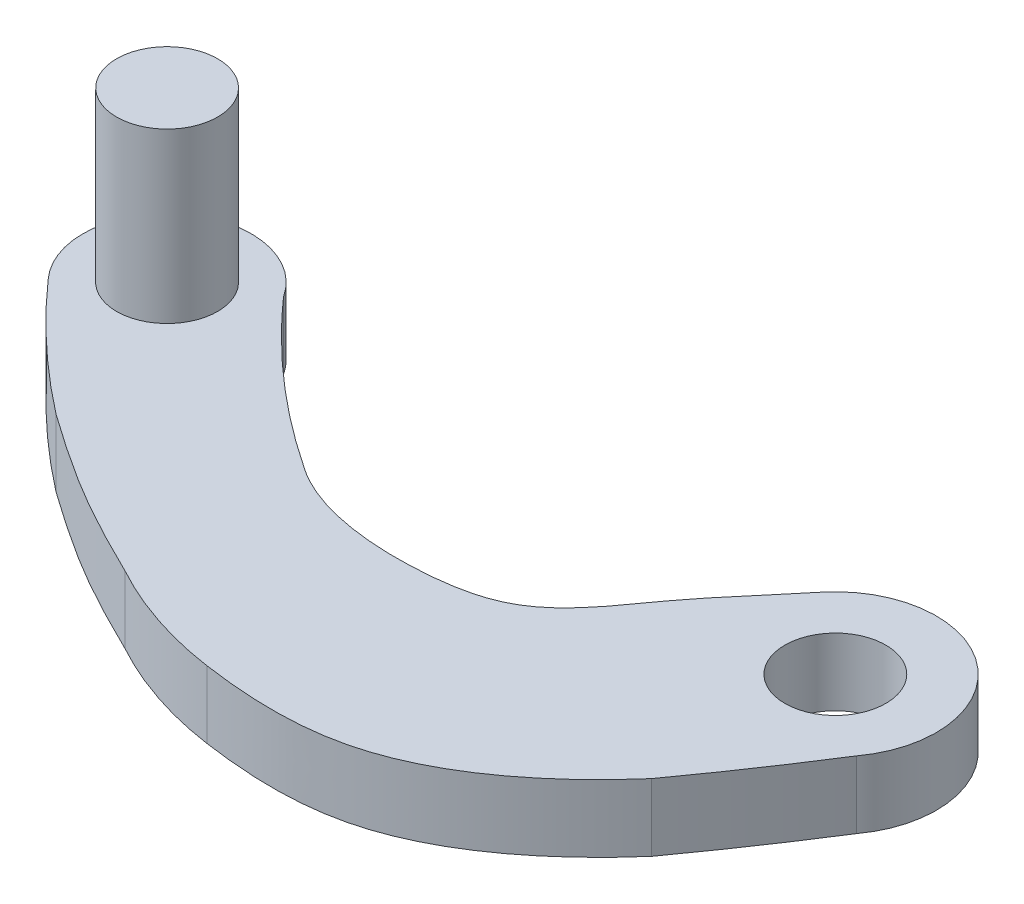
from build123d import *

# Parameters (mm, degrees)
SALIENTE_EXTRUIR1_DEPTH = 2
CROQUIS2_R              = 1.5
CORTAR_EXTRUIR2_DEPTH   = 3
CROQUIS4_R              = 1.5
SALIENTE_EXTRUIR3_DEPTH = 5


with BuildPart() as part:
    # Croquis1 → Saliente-Extruir1 (new body)
    with BuildSketch(Plane(origin=(0, 0, 0), x_dir=(1, 0, 0), z_dir=(0, 1, 0))):
        with BuildLine():
            add(Edge.make_bspline(
                [(-0.047552943, -5.41433386), (1.239779979, -3.635052884), (2.414610314, -1.780353063)],
                knots=[0, 0, 0, 1, 1, 1], degree=2))
            ThreePointArc((2.414610314, -1.780353063), (1.832628676, 2.375178338), (-2.334614821, 1.88403122))
            add(Edge.make_bspline(
                [(-2.334614821, 1.88403122), (-2.951325259, 1.119828741), (-4.509299118, -0.563300275), (-5.988366098, -3.121312175), (-9.777324233, -3.72498405), (-12.108475468, -3.349116626), (-13.205411179, -2.56941452)],
                knots=[0, 0, 0, 0, 0.210355785, 0.457410568, 0.578047142, 0.870899615, 0.870899615, 0.870899615, 0.870899615], degree=3))
            add(Edge.make_bspline(
                [(-13.205411179, -2.56941452), (-15.819352109, -0.83375271), (-17.897343033, 1.511058614)],
                knots=[0, 0, 0, 1, 1, 1], degree=2))
            ThreePointArc((-17.897343033, 1.511058614), (-21.528082135, 2.135894472), (-21.839041513, -1.535071415))
            add(Edge.make_bspline(
                [(-18.257712787, -4.881966223), (-20.206095591, -3.376965901), (-21.839041513, -1.535071415)],
                knots=[0, 0, 0, 1, 1, 1], degree=2))
            add(Edge.make_bspline(
                [(-13.205411179, -7.886532608), (-14.054265837, -7.471831244), (-15.806738264, -6.580922778), (-17.428856772, -5.469594286), (-18.257712787, -4.881966223)],
                knots=[0, 0, 0, 0, 0.481848673, 1, 1, 1, 1], degree=3))
            add(Edge.make_bspline(
                [(-9.554936668, -9.109021082), (-11.480606525, -8.82957168), (-13.205411179, -7.886532608)],
                knots=[0, 0, 0, 1, 1, 1], degree=2))
            add(Edge.make_bspline(
                [(-0.047552943, -5.41433386), (-1.436995415, -7.008044472), (-4.467557841, -9.495004111), (-8.188902662, -9.306395591), (-9.554936668, -9.109021082)],
                knots=[0, 0, 0, 0, 0.608220397, 1, 1, 1, 1], degree=3))
        make_face()
    extrude(amount=SALIENTE_EXTRUIR1_DEPTH)

    # Croquis2 → Cortar-Extruir2 (cut)
    with BuildSketch(Plane(origin=(0, 2, 0), x_dir=(1, 0, 0), z_dir=(0, 1, 0))):
        Circle(CROQUIS2_R)
    extrude(amount=-CORTAR_EXTRUIR2_DEPTH, mode=Mode.SUBTRACT)

    # Croquis4 → Saliente-Extruir3 (add)
    with BuildSketch(Plane(origin=(0, 2, 0), x_dir=(1, 0, 0), z_dir=(0, 1, 0))):
        with Locations((-19.999377879, 0.157748042)):
            Circle(CROQUIS4_R)
    extrude(amount=SALIENTE_EXTRUIR3_DEPTH)


solid = part.part
